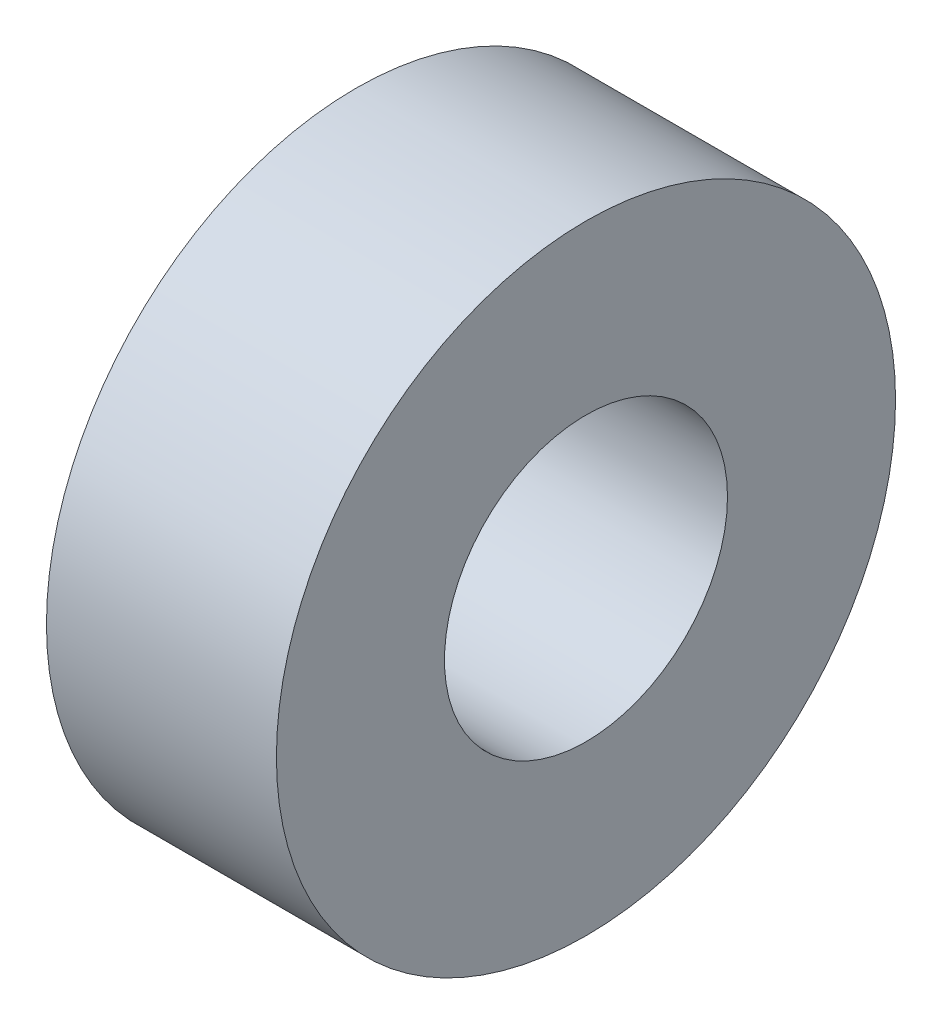
from build123d import *

# Parameters (mm, degrees)
SKETCH1_R           = 3.5
SKETCH1_R_2         = 1.6
BOSS_EXTRUDE1_DEPTH = 2.6


with BuildPart() as part:
    # Sketch1 → Boss-Extrude1 (new body)
    with BuildSketch(Plane(origin=(0, 0, 0), x_dir=(0, 0, -1), z_dir=(1, 0, 0))):
        Circle(SKETCH1_R)
        Circle(SKETCH1_R_2, mode=Mode.SUBTRACT)
    extrude(amount=BOSS_EXTRUDE1_DEPTH)


solid = part.part
